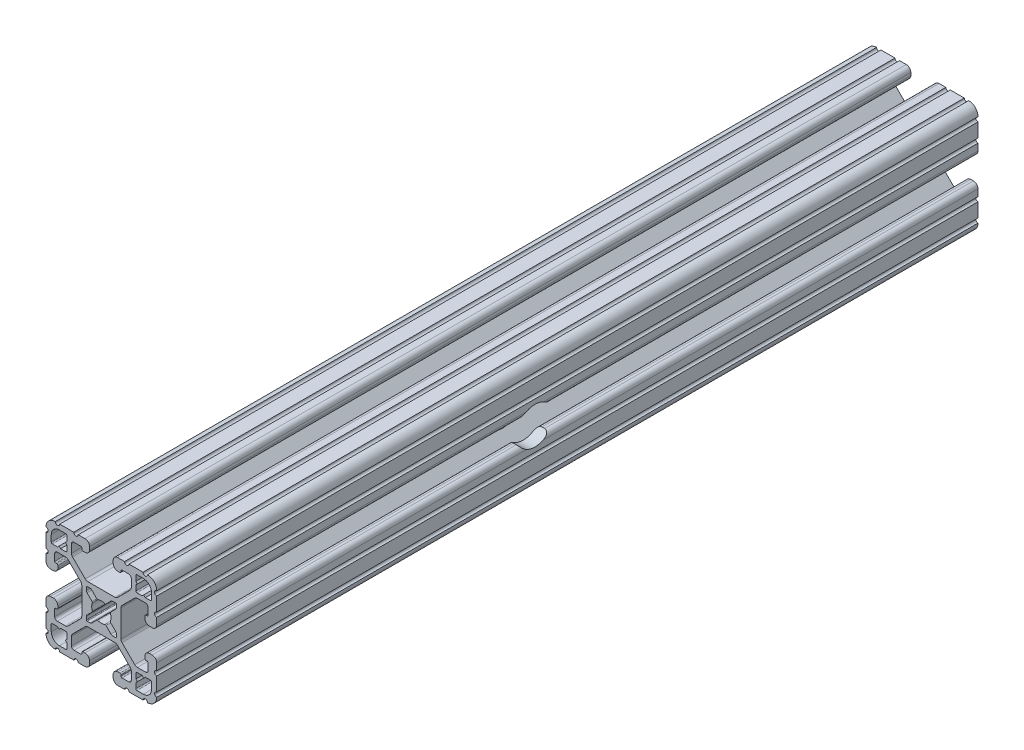
from build123d import *

# Parameters (mm, degrees)
BOSS_EXTRUDE1_DEPTH = 282.575
SKETCH2_R           = 6.35
CUT_EXTRUDE1_DEPTH  = 39.100000018


with BuildPart() as part:
    # Sketch1 → Boss-Extrude1 (new body)
    with BuildSketch(Plane(origin=(0, 0, -2322.576), x_dir=(-1, 0, 0), z_dir=(0, 0, -1))):
        with BuildLine():
            Line((19.05, -14.325600033), (19.05, -9.4996))
            ThreePointArc((19.05, -9.4996), (18.288, -8.7376), (19.05, -7.9756))
            Line((19.05, -7.9756), (19.05, -5.6388))
            ThreePointArc((19.05, -5.6388), (18.588751759, -4.525248241), (17.4752, -4.064))
            Line((17.4752, -4.064), (16.5608, -4.064))
            ThreePointArc((16.5608, -4.064), (15.447248241, -4.525248241), (14.986, -5.6388))
            Line((14.986, -5.6388), (14.986, -6.350014224))
            ThreePointArc((14.986, -6.350014224), (15.097592316, -6.619421908), (15.367, -6.731014224))
            Line((15.367, -6.731014224), (15.6972, -6.731014224))
            ThreePointArc((15.6972, -6.731014224), (15.966607684, -6.84260654), (16.0782, -7.112014224))
            Line((16.0782, -7.112014224), (16.0782, -9.398014224))
            ThreePointArc((16.0782, -9.398014224), (15.817817928, -10.026632152), (15.1892, -10.287014224))
            Line((15.1892, -10.287014224), (12.375630013, -10.287014224))
            ThreePointArc((12.375630013, -10.287014224), (11.889622054, -10.19034123), (11.477604401, -9.915039836))
            Line((11.477604401, -9.915039836), (7.115699788, -5.553135223))
            ThreePointArc((7.115699788, -5.553135223), (6.840398394, -5.14111757), (6.7437254, -4.655109611))
            Line((6.7437254, -4.655109611), (6.7437254, 4.655109611))
            ThreePointArc((6.7437254, 4.655109611), (6.840398394, 5.14111757), (7.115699788, 5.553135223))
            Line((7.115699788, 5.553135223), (11.477604401, 9.915039836))
            ThreePointArc((11.477604401, 9.915039836), (11.889622054, 10.19034123), (12.375630013, 10.287014224))
            Line((12.375630013, 10.287014224), (15.1892, 10.287014224))
            ThreePointArc((15.1892, 10.287014224), (15.817817928, 10.026632152), (16.0782, 9.398014224))
            Line((16.0782, 9.398014224), (16.0782, 7.112014224))
            ThreePointArc((16.0782, 7.112014224), (15.966607684, 6.84260654), (15.6972, 6.731014224))
            Line((15.6972, 6.731014224), (15.367, 6.731014224))
            ThreePointArc((15.367, 6.731014224), (15.097592316, 6.619421908), (14.986, 6.350014224))
            Line((14.986, 6.350014224), (14.986, 5.6388))
            ThreePointArc((14.986, 5.6388), (15.447248241, 4.525248241), (16.5608, 4.064))
            Line((16.5608, 4.064), (17.4752, 4.064))
            ThreePointArc((17.4752, 4.064), (18.588751759, 4.525248241), (19.05, 5.6388))
            Line((19.05, 5.6388), (19.05, 7.9756))
            ThreePointArc((19.05, 7.9756), (18.288, 8.7376), (19.05, 9.4996))
            Line((19.05, 9.4996), (19.05, 14.325599984))
            ThreePointArc((19.05, 14.325599984), (18.287999986, 15.087549208), (19.049898416, 15.849600009))
            ThreePointArc((19.049898416, 15.849600009), (18.120064036, 18.120064058), (15.849599977, 19.049898414))
            ThreePointArc((15.849599977, 19.049898414), (15.0875492, 18.288000035), (14.325600017, 19.050000016))
            Line((14.325600017, 19.050000016), (9.499600001, 19.050000016))
            ThreePointArc((9.499600001, 19.050000016), (8.737600001, 18.288000016), (7.975600001, 19.050000016))
            Line((7.975600001, 19.050000016), (5.638800016, 19.050000016))
            ThreePointArc((5.638800016, 19.050000016), (4.525248257, 18.588751775), (4.064000016, 17.475200016))
            Line((4.064000016, 17.475200016), (4.064000016, 16.5608))
            ThreePointArc((4.064000016, 16.5608), (4.525248257, 15.447248241), (5.638800016, 14.986))
            Line((5.638800016, 14.986), (6.350014224, 14.986))
            ThreePointArc((6.350014224, 14.986), (6.619421908, 15.097592316), (6.731014224, 15.367))
            Line((6.731014224, 15.367), (6.731014224, 15.6972))
            ThreePointArc((6.731014224, 15.6972), (6.84260654, 15.966607684), (7.112014224, 16.0782))
            Line((7.112014224, 16.0782), (9.398014224, 16.0782))
            ThreePointArc((9.398014224, 16.0782), (10.026632152, 15.817817928), (10.287014224, 15.1892))
            Line((10.287014224, 15.1892), (10.287014224, 12.375630013))
            ThreePointArc((10.287014224, 12.375630013), (10.19034123, 11.889622054), (9.915039836, 11.477604401))
            Line((9.915039836, 11.477604401), (5.553135223, 7.115699788))
            ThreePointArc((5.553135223, 7.115699788), (5.14111757, 6.840398394), (4.655109611, 6.7437254))
            Line((4.655109611, 6.7437254), (-4.655109611, 6.7437254))
            ThreePointArc((-4.655109611, 6.7437254), (-5.14111757, 6.840398394), (-5.553135223, 7.115699788))
            Line((-5.553135223, 7.115699788), (-9.915039836, 11.477604401))
            ThreePointArc((-9.915039836, 11.477604401), (-10.19034123, 11.889622054), (-10.287014224, 12.375630013))
            Line((-10.287014224, 12.375630013), (-10.287014224, 15.1892))
            ThreePointArc((-10.287014224, 15.1892), (-10.026632152, 15.817817928), (-9.398014224, 16.0782))
            Line((-9.398014224, 16.0782), (-7.112014224, 16.0782))
            ThreePointArc((-7.112014224, 16.0782), (-6.84260654, 15.966607684), (-6.731014224, 15.6972))
            Line((-6.731014224, 15.6972), (-6.731014224, 15.367))
            ThreePointArc((-6.731014224, 15.367), (-6.619421908, 15.097592316), (-6.350014224, 14.986))
            Line((-6.350014224, 14.986), (-5.638799984, 14.986))
            ThreePointArc((-5.638799984, 14.986), (-4.525248225, 15.447248241), (-4.063999984, 16.5608))
            Line((-4.063999984, 16.5608), (-4.063999984, 17.475200016))
            ThreePointArc((-4.063999984, 17.475200016), (-4.525248225, 18.588751775), (-5.638799984, 19.050000016))
            Line((-5.638799984, 19.050000016), (-7.975599999, 19.050000016))
            ThreePointArc((-7.975599999, 19.050000016), (-8.737599999, 18.288000016), (-9.499599999, 19.050000016))
            Line((-9.499599999, 19.050000016), (-14.325599999, 19.050000016))
            ThreePointArc((-14.325599999, 19.050000016), (-15.087549199, 18.288000018), (-15.849599993, 19.049898416))
            ThreePointArc((-15.849599993, 19.049898416), (-18.120064042, 18.120064036), (-19.049898398, 15.849599976))
            ThreePointArc((-19.049898398, 15.849599976), (-18.288000019, 15.087549199), (-19.05, 14.325600017))
            Line((-19.05, 14.325600017), (-19.05, 9.4996))
            ThreePointArc((-19.05, 9.4996), (-18.288, 8.7376), (-19.05, 7.9756))
            Line((-19.05, 7.9756), (-19.05, 5.6388))
            ThreePointArc((-19.05, 5.6388), (-18.588751759, 4.525248241), (-17.4752, 4.064))
            Line((-17.4752, 4.064), (-16.5608, 4.064))
            ThreePointArc((-16.5608, 4.064), (-15.447248241, 4.525248241), (-14.986, 5.6388))
            Line((-14.986, 5.6388), (-14.986, 6.350014224))
            ThreePointArc((-14.986, 6.350014224), (-15.097592316, 6.619421908), (-15.367, 6.731014224))
            Line((-15.367, 6.731014224), (-15.6972, 6.731014224))
            ThreePointArc((-15.6972, 6.731014224), (-15.966607684, 6.84260654), (-16.0782, 7.112014224))
            Line((-16.0782, 7.112014224), (-16.0782, 9.398014224))
            ThreePointArc((-16.0782, 9.398014224), (-15.817817928, 10.026632152), (-15.1892, 10.287014224))
            Line((-15.1892, 10.287014224), (-12.375630013, 10.287014224))
            ThreePointArc((-12.375630013, 10.287014224), (-11.889622054, 10.19034123), (-11.477604401, 9.915039836))
            Line((-11.477604401, 9.915039836), (-7.115699788, 5.553135223))
            ThreePointArc((-7.115699788, 5.553135223), (-6.840398394, 5.14111757), (-6.7437254, 4.655109611))
            Line((-6.7437254, 4.655109611), (-6.7437254, -4.655109611))
            ThreePointArc((-6.7437254, -4.655109611), (-6.840398394, -5.14111757), (-7.115699788, -5.553135223))
            Line((-7.115699788, -5.553135223), (-11.477604401, -9.915039836))
            ThreePointArc((-11.477604401, -9.915039836), (-11.889622054, -10.19034123), (-12.375630013, -10.287014224))
            Line((-12.375630013, -10.287014224), (-15.1892, -10.287014224))
            ThreePointArc((-15.1892, -10.287014224), (-15.817817928, -10.026632152), (-16.0782, -9.398014224))
            Line((-16.0782, -9.398014224), (-16.0782, -7.112014224))
            ThreePointArc((-16.0782, -7.112014224), (-15.966607684, -6.84260654), (-15.6972, -6.731014224))
            Line((-15.6972, -6.731014224), (-15.367, -6.731014224))
            ThreePointArc((-15.367, -6.731014224), (-15.097592316, -6.619421908), (-14.986, -6.350014224))
            Line((-14.986, -6.350014224), (-14.986, -5.6388))
            ThreePointArc((-14.986, -5.6388), (-15.447248241, -4.525248241), (-16.5608, -4.064))
            Line((-16.5608, -4.064), (-17.4752, -4.064))
            ThreePointArc((-17.4752, -4.064), (-18.588751759, -4.525248241), (-19.05, -5.6388))
            Line((-19.05, -5.6388), (-19.05, -7.9756))
            ThreePointArc((-19.05, -7.9756), (-18.288, -8.7376), (-19.05, -9.4996))
            Line((-19.05, -9.4996), (-19.05, -14.3256))
            ThreePointArc((-19.05, -14.3256), (-18.288000002, -15.0875492), (-19.0498984, -15.849599993))
            ThreePointArc((-19.0498984, -15.849599993), (-18.120064019, -18.120064043), (-15.84959996, -19.049898399))
            ThreePointArc((-15.84959996, -19.049898399), (-15.087549183, -18.288000019), (-14.325600001, -19.050000001))
            Line((-14.325600001, -19.050000001), (-9.499599984, -19.050000001))
            ThreePointArc((-9.499599984, -19.050000001), (-8.737599984, -18.288000001), (-7.975599984, -19.050000001))
            Line((-7.975599984, -19.050000001), (-5.638799984, -19.050000001))
            ThreePointArc((-5.638799984, -19.050000001), (-4.525248225, -18.58875176), (-4.063999984, -17.475200001))
            Line((-4.063999984, -17.475200001), (-4.063999984, -16.5608))
            ThreePointArc((-4.063999984, -16.5608), (-4.525248225, -15.447248241), (-5.638799984, -14.986))
            Line((-5.638799984, -14.986), (-6.350014224, -14.986))
            ThreePointArc((-6.350014224, -14.986), (-6.619421908, -15.097592316), (-6.731014224, -15.367))
            Line((-6.731014224, -15.367), (-6.731014224, -15.6972))
            ThreePointArc((-6.731014224, -15.6972), (-6.84260654, -15.966607684), (-7.112014224, -16.0782))
            Line((-7.112014224, -16.0782), (-9.398014224, -16.0782))
            ThreePointArc((-9.398014224, -16.0782), (-10.026632152, -15.817817928), (-10.287014224, -15.1892))
            Line((-10.287014224, -15.1892), (-10.287014224, -12.375630013))
            ThreePointArc((-10.287014224, -12.375630013), (-10.19034123, -11.889622054), (-9.915039836, -11.477604401))
            Line((-9.915039836, -11.477604401), (-5.553135223, -7.115699788))
            ThreePointArc((-5.553135223, -7.115699788), (-5.14111757, -6.840398394), (-4.655109611, -6.7437254))
            Line((-4.655109611, -6.7437254), (4.655109611, -6.7437254))
            ThreePointArc((4.655109611, -6.7437254), (5.14111757, -6.840398394), (5.553135223, -7.115699788))
            Line((5.553135223, -7.115699788), (9.915039836, -11.477604401))
            ThreePointArc((9.915039836, -11.477604401), (10.19034123, -11.889622054), (10.287014224, -12.375630013))
            Line((10.287014224, -12.375630013), (10.287014224, -15.1892))
            ThreePointArc((10.287014224, -15.1892), (10.026632152, -15.817817928), (9.398014224, -16.0782))
            Line((9.398014224, -16.0782), (7.112014224, -16.0782))
            ThreePointArc((7.112014224, -16.0782), (6.84260654, -15.966607684), (6.731014224, -15.6972))
            Line((6.731014224, -15.6972), (6.731014224, -15.367))
            ThreePointArc((6.731014224, -15.367), (6.619421908, -15.097592316), (6.350014224, -14.986))
            Line((6.350014224, -14.986), (5.638800016, -14.986))
            ThreePointArc((5.638800016, -14.986), (4.525248257, -15.447248241), (4.064000016, -16.5608))
            Line((4.064000016, -16.5608), (4.064000016, -17.475200001))
            ThreePointArc((4.064000016, -17.475200001), (4.525248257, -18.58875176), (5.638800016, -19.050000001))
            Line((5.638800016, -19.050000001), (7.975600016, -19.050000001))
            ThreePointArc((7.975600016, -19.050000001), (8.737600016, -18.288000001), (9.499600016, -19.050000001))
            Line((9.499600016, -19.050000001), (14.325600016, -19.050000001))
            ThreePointArc((14.325600016, -19.050000001), (15.087549216, -18.288000002), (15.849600009, -19.0498984))
            ThreePointArc((15.849600009, -19.0498984), (18.120064059, -18.12006402), (19.049898415, -15.849599961))
            ThreePointArc((19.049898415, -15.849599961), (18.288000034, -15.087549207), (19.05, -14.325600033))
        make_face()
        with BuildLine():
            Line((17.246614224, 14.452614224), (17.246614224, 12.242814224))
            ThreePointArc((17.246614224, 12.242814224), (17.135021908, 11.97340654), (16.865614224, 11.861814224))
            Line((16.865614224, 11.861814224), (15.092694224, 11.861814224))
            Line((15.092694224, 11.861814224), (14.554214224, 12.400294224))
            Line((14.554214224, 12.400294224), (14.015734224, 11.861814224))
            Line((14.015734224, 11.861814224), (12.242814224, 11.861814224))
            ThreePointArc((12.242814224, 11.861814224), (11.97340654, 11.97340654), (11.861814224, 12.242814224))
            Line((11.861814224, 12.242814224), (11.861814224, 14.015734224))
            Line((11.861814224, 14.015734224), (12.400294224, 14.554214224))
            Line((12.400294224, 14.554214224), (11.861814224, 15.092694224))
            Line((11.861814224, 15.092694224), (11.861814224, 16.865614224))
            ThreePointArc((11.861814224, 16.865614224), (11.97340654, 17.135021908), (12.242814224, 17.246614224))
            Line((12.242814224, 17.246614224), (14.452614224, 17.246614224))
            ThreePointArc((14.452614224, 17.246614224), (16.428270571, 16.428270571), (17.246614224, 14.452614224))
        make_face(mode=Mode.SUBTRACT)
        with BuildLine():
            Line((17.246614224, -12.242814224), (17.246614224, -14.452614224))
            ThreePointArc((17.246614224, -14.452614224), (16.428270571, -16.428270571), (14.452614224, -17.246614224))
            Line((14.452614224, -17.246614224), (12.242814224, -17.246614224))
            ThreePointArc((12.242814224, -17.246614224), (11.97340654, -17.135021908), (11.861814224, -16.865614224))
            Line((11.861814224, -16.865614224), (11.861814224, -15.092694224))
            Line((11.861814224, -15.092694224), (12.400294224, -14.554214224))
            Line((12.400294224, -14.554214224), (11.861814224, -14.015734224))
            Line((11.861814224, -14.015734224), (11.861814224, -12.242814224))
            ThreePointArc((11.861814224, -12.242814224), (11.97340654, -11.97340654), (12.242814224, -11.861814224))
            Line((12.242814224, -11.861814224), (14.015734224, -11.861814224))
            Line((14.015734224, -11.861814224), (14.554214224, -12.400294224))
            Line((14.554214224, -12.400294224), (15.092694224, -11.861814224))
            Line((15.092694224, -11.861814224), (16.865614224, -11.861814224))
            ThreePointArc((16.865614224, -11.861814224), (17.135021908, -11.97340654), (17.246614224, -12.242814224))
        make_face(mode=Mode.SUBTRACT)
        with BuildLine():
            Line((5.1689, -3.920689755), (5.1689, -4.9149))
            ThreePointArc((5.1689, -4.9149), (5.094505122, -5.094505122), (4.9149, -5.1689))
            Line((4.9149, -5.1689), (3.920689755, -5.1689))
            ThreePointArc((3.920689755, -5.1689), (3.580484184, -5.101228904), (3.292071827, -4.908517928))
            Line((3.292071827, -4.908517928), (1.582347442, -3.198793543))
            ThreePointArc((1.582347442, -3.198793543), (1.393016011, -3.095711236), (1.178048687, -3.111879183))
            ThreePointArc((1.178048687, -3.111879183), (0, -3.3274), (-1.178048687, -3.111879183))
            ThreePointArc((-1.178048687, -3.111879183), (-1.393016011, -3.095711236), (-1.582347442, -3.198793543))
            Line((-1.582347442, -3.198793543), (-3.292071827, -4.908517928))
            ThreePointArc((-3.292071827, -4.908517928), (-3.580484184, -5.101228904), (-3.920689755, -5.1689))
            Line((-3.920689755, -5.1689), (-4.9149, -5.1689))
            ThreePointArc((-4.9149, -5.1689), (-5.094505122, -5.094505122), (-5.1689, -4.9149))
            Line((-5.1689, -4.9149), (-5.1689, -3.920689755))
            ThreePointArc((-5.1689, -3.920689755), (-5.101228904, -3.580484184), (-4.908517928, -3.292071827))
            Line((-4.908517928, -3.292071827), (-3.198793543, -1.582347442))
            ThreePointArc((-3.198793543, -1.582347442), (-3.095711236, -1.393016011), (-3.111879183, -1.178048687))
            ThreePointArc((-3.111879183, -1.178048687), (-3.3274, 0), (-3.111879183, 1.178048687))
            ThreePointArc((-3.111879183, 1.178048687), (-3.095711236, 1.393016011), (-3.198793543, 1.582347442))
            Line((-3.198793543, 1.582347442), (-4.908517928, 3.292071827))
            ThreePointArc((-4.908517928, 3.292071827), (-5.101228904, 3.580484184), (-5.1689, 3.920689755))
            Line((-5.1689, 3.920689755), (-5.1689, 4.9149))
            ThreePointArc((-5.1689, 4.9149), (-5.094505122, 5.094505122), (-4.9149, 5.1689))
            Line((-4.9149, 5.1689), (-3.920689755, 5.1689))
            ThreePointArc((-3.920689755, 5.1689), (-3.580484184, 5.101228904), (-3.292071827, 4.908517928))
            Line((-3.292071827, 4.908517928), (-1.582347442, 3.198793543))
            ThreePointArc((-1.582347442, 3.198793543), (-1.393016011, 3.095711236), (-1.178048687, 3.111879183))
            ThreePointArc((-1.178048687, 3.111879183), (0, 3.3274), (1.178048687, 3.111879183))
            ThreePointArc((1.178048687, 3.111879183), (1.393016011, 3.095711236), (1.582347442, 3.198793543))
            Line((1.582347442, 3.198793543), (3.292071827, 4.908517928))
            ThreePointArc((3.292071827, 4.908517928), (3.580484184, 5.101228904), (3.920689755, 5.1689))
            Line((3.920689755, 5.1689), (4.9149, 5.1689))
            ThreePointArc((4.9149, 5.1689), (5.094505122, 5.094505122), (5.1689, 4.9149))
            Line((5.1689, 4.9149), (5.1689, 3.920689755))
            ThreePointArc((5.1689, 3.920689755), (5.101228904, 3.580484184), (4.908517928, 3.292071827))
            Line((4.908517928, 3.292071827), (3.198793543, 1.582347442))
            ThreePointArc((3.198793543, 1.582347442), (3.095711236, 1.393016011), (3.111879183, 1.178048687))
            ThreePointArc((3.111879183, 1.178048687), (3.3274, 0), (3.111879183, -1.178048687))
            ThreePointArc((3.111879183, -1.178048687), (3.095711236, -1.393016011), (3.198793543, -1.582347442))
            Line((3.198793543, -1.582347442), (4.908517928, -3.292071827))
            ThreePointArc((4.908517928, -3.292071827), (5.101228904, -3.580484184), (5.1689, -3.920689755))
        make_face(mode=Mode.SUBTRACT)
        with BuildLine():
            Line((-11.861814224, -12.242814224), (-11.861814224, -14.015734224))
            Line((-11.861814224, -14.015734224), (-12.400294224, -14.554214224))
            Line((-12.400294224, -14.554214224), (-11.861814224, -15.092694224))
            Line((-11.861814224, -15.092694224), (-11.861814224, -16.865614224))
            ThreePointArc((-11.861814224, -16.865614224), (-11.97340654, -17.135021908), (-12.242814224, -17.246614224))
            Line((-12.242814224, -17.246614224), (-14.452614224, -17.246614224))
            ThreePointArc((-14.452614224, -17.246614224), (-16.428270571, -16.428270571), (-17.246614224, -14.452614224))
            Line((-17.246614224, -14.452614224), (-17.246614224, -12.242814224))
            ThreePointArc((-17.246614224, -12.242814224), (-17.135021908, -11.97340654), (-16.865614224, -11.861814224))
            Line((-16.865614224, -11.861814224), (-15.092694224, -11.861814224))
            Line((-15.092694224, -11.861814224), (-14.554214224, -12.400294224))
            Line((-14.554214224, -12.400294224), (-14.015734224, -11.861814224))
            Line((-14.015734224, -11.861814224), (-12.242814224, -11.861814224))
            ThreePointArc((-12.242814224, -11.861814224), (-11.97340654, -11.97340654), (-11.861814224, -12.242814224))
        make_face(mode=Mode.SUBTRACT)
        with BuildLine():
            Line((-11.861814224, 16.865614224), (-11.861814224, 15.092694224))
            Line((-11.861814224, 15.092694224), (-12.400294224, 14.554214224))
            Line((-12.400294224, 14.554214224), (-11.861814224, 14.015734224))
            Line((-11.861814224, 14.015734224), (-11.861814224, 12.242814224))
            ThreePointArc((-11.861814224, 12.242814224), (-11.97340654, 11.97340654), (-12.242814224, 11.861814224))
            Line((-12.242814224, 11.861814224), (-14.015734224, 11.861814224))
            Line((-14.015734224, 11.861814224), (-14.554214224, 12.400294224))
            Line((-14.554214224, 12.400294224), (-15.092694224, 11.861814224))
            Line((-15.092694224, 11.861814224), (-16.865614224, 11.861814224))
            ThreePointArc((-16.865614224, 11.861814224), (-17.135021908, 11.97340654), (-17.246614224, 12.242814224))
            Line((-17.246614224, 12.242814224), (-17.246614224, 14.452614224))
            ThreePointArc((-17.246614224, 14.452614224), (-16.428270571, 16.428270571), (-14.452614224, 17.246614224))
            Line((-14.452614224, 17.246614224), (-12.242814224, 17.246614224))
            ThreePointArc((-12.242814224, 17.246614224), (-11.97340654, 17.135021908), (-11.861814224, 16.865614224))
        make_face(mode=Mode.SUBTRACT)
    extrude(amount=-BOSS_EXTRUDE1_DEPTH)

    # Sketch2 → Cut-Extrude1 (cut, through all)
    with BuildSketch(Plane(origin=(19.05, 0, 0), x_dir=(0, 0, -1), z_dir=(1, 0, 0))):
        with Locations((2170.176, 0)):
            Circle(SKETCH2_R)
    extrude(amount=-CUT_EXTRUDE1_DEPTH, mode=Mode.SUBTRACT)


solid = part.part
